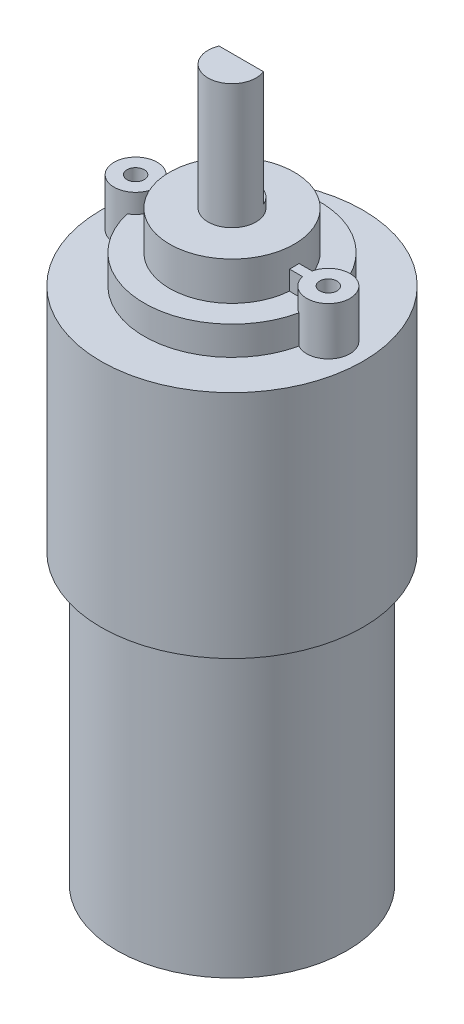
from build123d import *

# Parameters (mm, degrees)
CROQUIS1_W              = 2.5
CROQUIS1_H              = 13
CORTAR_EXTRUIR1_DEPTH   = 12
CROQUIS4_R              = 2.25
CROQUIS4_R_2            = 0.9
CROQUIS4_W              = 18
CROQUIS4_H              = 1
SALIENTE_EXTRUIR1_DEPTH = 5


with BuildPart() as part:
    # Croquis1 → Revolución1 (revolve)
    with BuildSketch(Plane.XY):
        with Locations((-1.25, 37)):
            Rectangle(CROQUIS1_W, CROQUIS1_H)
        Polygon((-12, -30.5), (0, -30.5), (0, 30.5), (-6.5, 30.5), (-6.5, 26.5), (-9.15, 26.5), (-9.15, 23.5), (-13.65, 23.5), (-13.65, -0.5), (-12, -0.5), align=None)
    revolve(axis=Axis((0, 65.687156563, 0), (0, -1, 0)))

    # Croquis2 → Cortar-Extruir1 (cut)
    with BuildSketch(Plane(origin=(0, 43.5, 0), x_dir=(1, 0, 0), z_dir=(0, 1, 0))):
        Polygon((-55.580517034, 0.96), (-2.308332732, 0.96), (2.308332732, 0.96), (55.580517034, 0.96), (55.580517034, 107.504368605), (-55.580517034, 107.504368605), align=None)
    extrude(amount=-CORTAR_EXTRUIR1_DEPTH, mode=Mode.SUBTRACT)

    # Croquis4 → Saliente-Extruir1 (add)
    with BuildSketch(Plane(origin=(0, 23.5, 0), x_dir=(1, 0, 0), z_dir=(0, 1, 0))):
        with Locations((-10.04, 0)):
            Circle(CROQUIS4_R)
        with Locations((-10.04, 0)):
            Circle(CROQUIS4_R_2, mode=Mode.SUBTRACT)
        with Locations((10.04, 0)):
            Circle(CROQUIS4_R)
        with Locations((10.04, 0)):
            Circle(CROQUIS4_R_2, mode=Mode.SUBTRACT)
        Rectangle(CROQUIS4_W, CROQUIS4_H)
    extrude(amount=SALIENTE_EXTRUIR1_DEPTH)


solid = part.part
